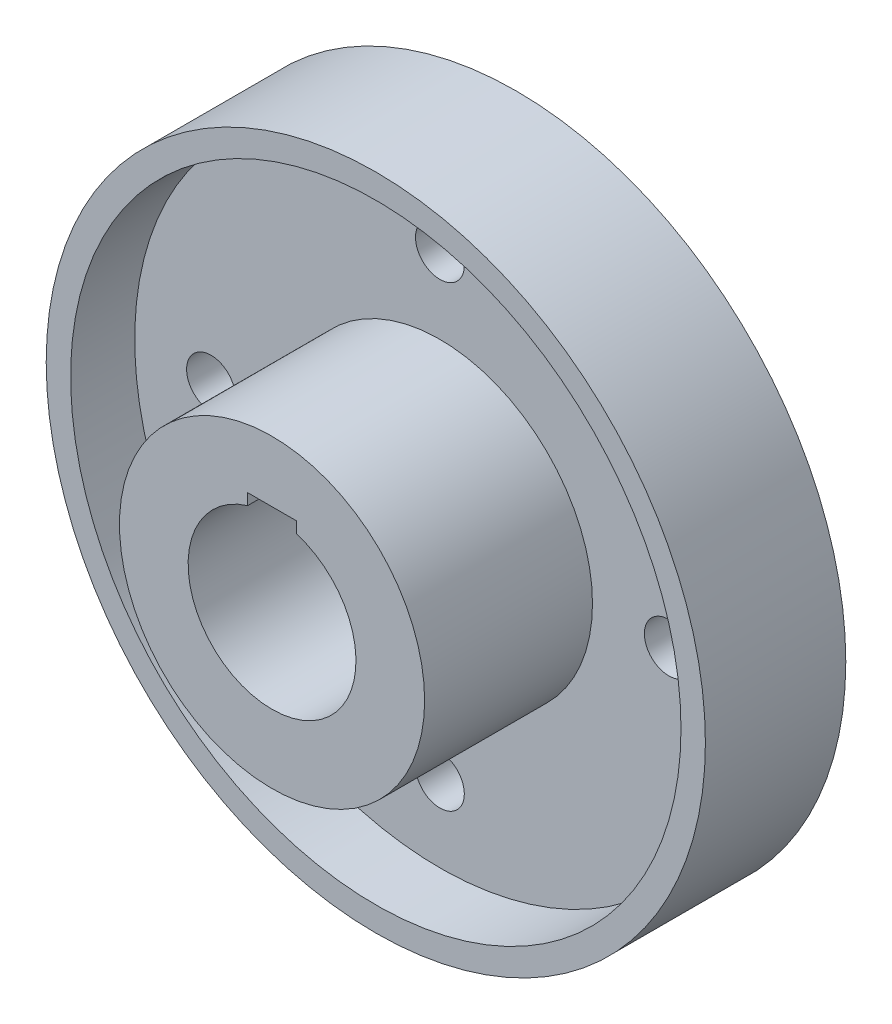
from build123d import *

# Parameters (mm, degrees)
SKETCH1_R           = 108
BOSS_EXTRUDE1_DEPTH = 25
SKETCH2_R           = 108
SKETCH2_R_2         = 100
BOSS_EXTRUDE2_DEPTH = 21
SKETCH3_R           = 50
SKETCH3_R_2         = 27.5
BOSS_EXTRUDE3_DEPTH = 55
SKETCH4_R           = 37.5
BOSS_EXTRUDE4_DEPTH = 5
SKETCH6_R           = 27.5
CUT_EXTRUDE1_DEPTH  = 31
SKETCH7_R           = 8
CUT_EXTRUDE2_DEPTH  = 31
SKETCH9_W           = 16
SKETCH9_H           = 30
CUT_EXTRUDE4_DEPTH  = 86


with BuildPart() as part:
    # Sketch1 → Boss-Extrude1 (new body)
    with BuildSketch(Plane.XY):
        Circle(SKETCH1_R)
    extrude(amount=BOSS_EXTRUDE1_DEPTH)

    # Sketch2 → Boss-Extrude2 (add)
    with BuildSketch(Plane.XY.offset(25)):
        Circle(SKETCH2_R)
        Circle(SKETCH2_R_2, mode=Mode.SUBTRACT)
    extrude(amount=BOSS_EXTRUDE2_DEPTH)

    # Sketch3 → Boss-Extrude3 (add)
    with BuildSketch(Plane.XY.offset(25)):
        Circle(SKETCH3_R)
        Circle(SKETCH3_R_2, mode=Mode.SUBTRACT)
    extrude(amount=BOSS_EXTRUDE3_DEPTH)

    # Sketch4 → Boss-Extrude4 (add)
    with BuildSketch(Plane(origin=(0, 0, 0), x_dir=(-1, 0, 0), z_dir=(0, 0, -1))):
        Circle(SKETCH4_R)
    extrude(amount=BOSS_EXTRUDE4_DEPTH)

    # Sketch6 → Cut-Extrude1 (cut, through all)
    with BuildSketch(Plane.XY.offset(25)):
        Circle(SKETCH6_R)
    extrude(amount=-CUT_EXTRUDE1_DEPTH, mode=Mode.SUBTRACT)

    # Sketch7 → Cut-Extrude2 (cut, through all)
    with BuildSketch(Plane.XY.offset(25)):
        with Locations((0, 75)):
            Circle(SKETCH7_R)
        with Locations((75, 0)):
            Circle(SKETCH7_R)
        with Locations((0, -75)):
            Circle(SKETCH7_R)
        with Locations((-75, 0)):
            Circle(SKETCH7_R)
    extrude(amount=-CUT_EXTRUDE2_DEPTH, mode=Mode.SUBTRACT)

    # Sketch9 → Cut-Extrude4 (cut, through all)
    with BuildSketch(Plane.XY.offset(80)):
        with Locations((0, 15)):
            Rectangle(SKETCH9_W, SKETCH9_H)
    extrude(amount=-CUT_EXTRUDE4_DEPTH, mode=Mode.SUBTRACT)


solid = part.part
